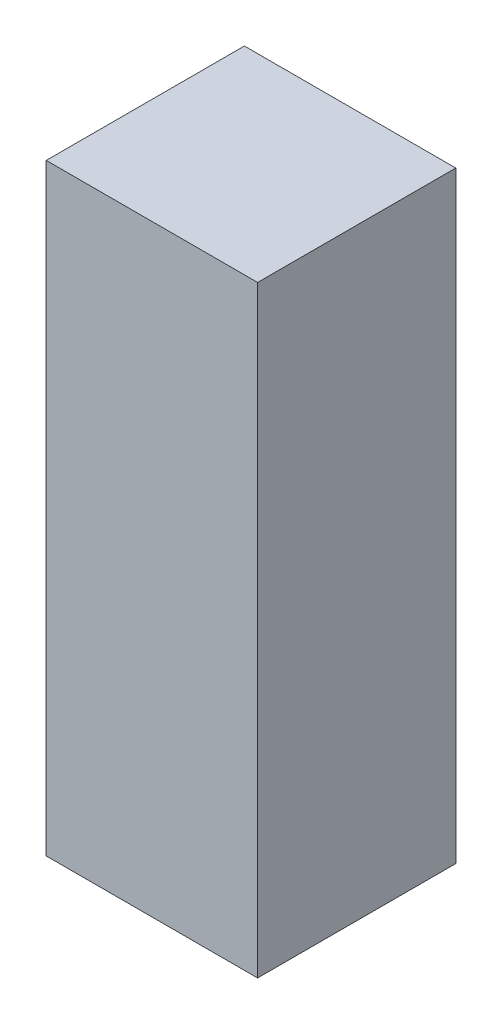
from build123d import *

# Parameters (mm, degrees)
SKETCH2_W           = 48
SKETCH2_H           = 45
BOSS_EXTRUDE1_DEPTH = 136.8


with BuildPart() as part:
    # Sketch2 → Boss-Extrude1 (new body)
    with BuildSketch(Plane(origin=(0, 0, 0), x_dir=(1, 0, 0), z_dir=(0, 1, 0))):
        Rectangle(SKETCH2_W, SKETCH2_H)
    extrude(amount=BOSS_EXTRUDE1_DEPTH)


solid = part.part
